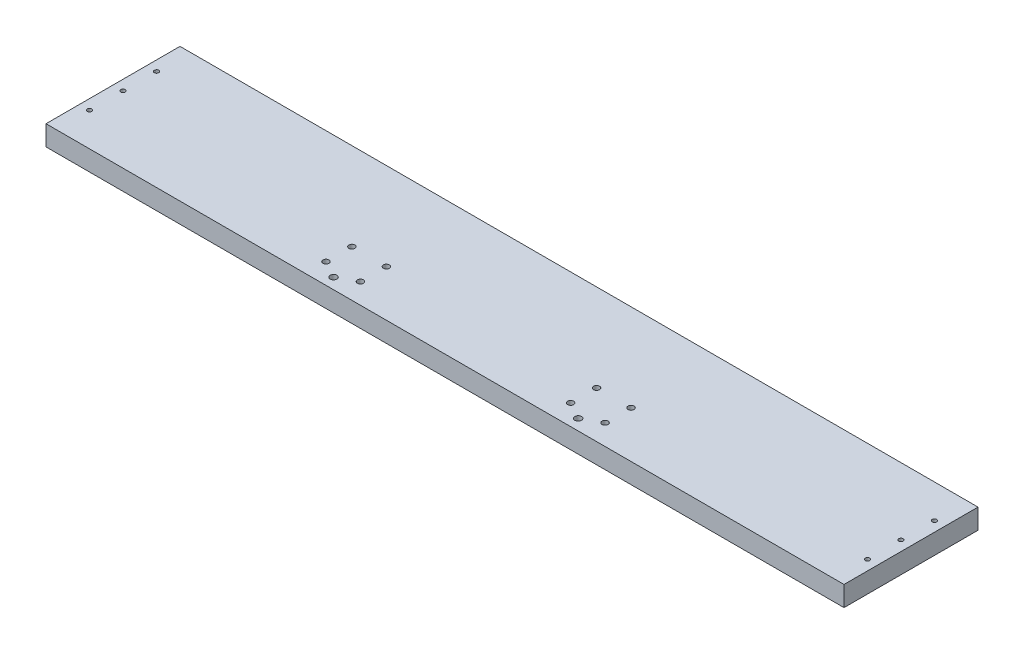
from build123d import *

# Parameters (mm, degrees)
SKETCH2_W           = 756.412
SKETCH2_H           = 127
BOSS_EXTRUDE1_DEPTH = 19.05
CUT_EXTRUDE1_REACH  = 21.05
SKETCH3_R           = 2.85115
CUT_EXTRUDE2_REACH  = 21.05
SKETCH4_R           = 3.175
CUT_EXTRUDE3_REACH  = 21.05
SKETCH5_R           = 2.0828


with BuildPart() as part:
    # Sketch2 → Boss-Extrude1 (new body)
    with BuildSketch(Plane(origin=(0, 0, 0), x_dir=(1, 0, 0), z_dir=(0, 1, 0))):
        with Locations((378.206, 63.5)):
            Rectangle(SKETCH2_W, SKETCH2_H)
    extrude(amount=BOSS_EXTRUDE1_DEPTH)

    # Sketch3 → Cut-Extrude1 (cut, up to next)
    with BuildSketch(Plane(origin=(0, 19.05, 0), x_dir=(1, 0, 0), z_dir=(0, 1, 0)), mode=Mode.PRIVATE) as cut_extrude1_sk1:
        with Locations((245.92915, 19.46275)):
            Circle(SKETCH3_R)
    cut_extrude1_tool1 = extrude(cut_extrude1_sk1.sketch, amount=-CUT_EXTRUDE1_REACH, mode=Mode.PRIVATE) & part.part
    add(cut_extrude1_tool1.solids().sort_by_distance((245.92915, 19.05, -19.46275))[0], mode=Mode.SUBTRACT)
    # Sketch3 → Cut-Extrude1 (cut, up to next)
    with BuildSketch(Plane(origin=(0, 19.05, 0), x_dir=(1, 0, 0), z_dir=(0, 1, 0)), mode=Mode.PRIVATE) as cut_extrude1_sk2:
        with Locations((278.58085, 19.46275)):
            Circle(SKETCH3_R)
    cut_extrude1_tool2 = extrude(cut_extrude1_sk2.sketch, amount=-CUT_EXTRUDE1_REACH, mode=Mode.PRIVATE) & part.part
    add(cut_extrude1_tool2.solids().sort_by_distance((278.58085, 19.05, -19.46275))[0], mode=Mode.SUBTRACT)
    # Sketch3 → Cut-Extrude1 (cut, up to next)
    with BuildSketch(Plane(origin=(0, 19.05, 0), x_dir=(1, 0, 0), z_dir=(0, 1, 0)), mode=Mode.PRIVATE) as cut_extrude1_sk3:
        with Locations((278.58085, 44.03725)):
            Circle(SKETCH3_R)
    cut_extrude1_tool3 = extrude(cut_extrude1_sk3.sketch, amount=-CUT_EXTRUDE1_REACH, mode=Mode.PRIVATE) & part.part
    add(cut_extrude1_tool3.solids().sort_by_distance((278.58085, 19.05, -44.03725))[0], mode=Mode.SUBTRACT)
    # Sketch3 → Cut-Extrude1 (cut, up to next)
    with BuildSketch(Plane(origin=(0, 19.05, 0), x_dir=(1, 0, 0), z_dir=(0, 1, 0)), mode=Mode.PRIVATE) as cut_extrude1_sk4:
        with Locations((245.92915, 44.03725)):
            Circle(SKETCH3_R)
    cut_extrude1_tool4 = extrude(cut_extrude1_sk4.sketch, amount=-CUT_EXTRUDE1_REACH, mode=Mode.PRIVATE) & part.part
    add(cut_extrude1_tool4.solids().sort_by_distance((245.92915, 19.05, -44.03725))[0], mode=Mode.SUBTRACT)
    # Sketch3 → Cut-Extrude1 (cut, up to next)
    with BuildSketch(Plane(origin=(0, 19.05, 0), x_dir=(1, 0, 0), z_dir=(0, 1, 0)), mode=Mode.PRIVATE) as cut_extrude1_sk5:
        with Locations((477.83115, 19.46275)):
            Circle(SKETCH3_R)
    cut_extrude1_tool5 = extrude(cut_extrude1_sk5.sketch, amount=-CUT_EXTRUDE1_REACH, mode=Mode.PRIVATE) & part.part
    add(cut_extrude1_tool5.solids().sort_by_distance((477.83115, 19.05, -19.46275))[0], mode=Mode.SUBTRACT)
    # Sketch3 → Cut-Extrude1 (cut, up to next)
    with BuildSketch(Plane(origin=(0, 19.05, 0), x_dir=(1, 0, 0), z_dir=(0, 1, 0)), mode=Mode.PRIVATE) as cut_extrude1_sk6:
        with Locations((510.48285, 19.46275)):
            Circle(SKETCH3_R)
    cut_extrude1_tool6 = extrude(cut_extrude1_sk6.sketch, amount=-CUT_EXTRUDE1_REACH, mode=Mode.PRIVATE) & part.part
    add(cut_extrude1_tool6.solids().sort_by_distance((510.48285, 19.05, -19.46275))[0], mode=Mode.SUBTRACT)
    # Sketch3 → Cut-Extrude1 (cut, up to next)
    with BuildSketch(Plane(origin=(0, 19.05, 0), x_dir=(1, 0, 0), z_dir=(0, 1, 0)), mode=Mode.PRIVATE) as cut_extrude1_sk7:
        with Locations((510.48285, 44.03725)):
            Circle(SKETCH3_R)
    cut_extrude1_tool7 = extrude(cut_extrude1_sk7.sketch, amount=-CUT_EXTRUDE1_REACH, mode=Mode.PRIVATE) & part.part
    add(cut_extrude1_tool7.solids().sort_by_distance((510.48285, 19.05, -44.03725))[0], mode=Mode.SUBTRACT)
    # Sketch3 → Cut-Extrude1 (cut, up to next)
    with BuildSketch(Plane(origin=(0, 19.05, 0), x_dir=(1, 0, 0), z_dir=(0, 1, 0)), mode=Mode.PRIVATE) as cut_extrude1_sk8:
        with Locations((477.83115, 44.03725)):
            Circle(SKETCH3_R)
    cut_extrude1_tool8 = extrude(cut_extrude1_sk8.sketch, amount=-CUT_EXTRUDE1_REACH, mode=Mode.PRIVATE) & part.part
    add(cut_extrude1_tool8.solids().sort_by_distance((477.83115, 19.05, -44.03725))[0], mode=Mode.SUBTRACT)

    # Sketch4 → Cut-Extrude2 (cut, up to next)
    with BuildSketch(Plane(origin=(0, 19.05, 0), x_dir=(1, 0, 0), z_dir=(0, 1, 0)), mode=Mode.PRIVATE) as cut_extrude2_sk1:
        with Locations((494.157, 10.31875)):
            Circle(SKETCH4_R)
    cut_extrude2_tool1 = extrude(cut_extrude2_sk1.sketch, amount=-CUT_EXTRUDE2_REACH, mode=Mode.PRIVATE) & part.part
    add(cut_extrude2_tool1.solids().sort_by_distance((494.157, 19.05, -10.31875))[0], mode=Mode.SUBTRACT)
    # Sketch4 → Cut-Extrude2 (cut, up to next)
    with BuildSketch(Plane(origin=(0, 19.05, 0), x_dir=(1, 0, 0), z_dir=(0, 1, 0)), mode=Mode.PRIVATE) as cut_extrude2_sk2:
        with Locations((262.255, 10.31875)):
            Circle(SKETCH4_R)
    cut_extrude2_tool2 = extrude(cut_extrude2_sk2.sketch, amount=-CUT_EXTRUDE2_REACH, mode=Mode.PRIVATE) & part.part
    add(cut_extrude2_tool2.solids().sort_by_distance((262.255, 19.05, -10.31875))[0], mode=Mode.SUBTRACT)

    # Sketch5 → Cut-Extrude3 (cut, up to next)
    with BuildSketch(Plane(origin=(0, 19.05, 0), x_dir=(1, 0, 0), z_dir=(0, 1, 0)), mode=Mode.PRIVATE) as cut_extrude3_sk1:
        with Locations((9.525, 95.25)):
            Circle(SKETCH5_R)
    cut_extrude3_tool1 = extrude(cut_extrude3_sk1.sketch, amount=-CUT_EXTRUDE3_REACH, mode=Mode.PRIVATE) & part.part
    add(cut_extrude3_tool1.solids().sort_by_distance((9.525, 19.05, -95.25))[0], mode=Mode.SUBTRACT)
    # Sketch5 → Cut-Extrude3 (cut, up to next)
    with BuildSketch(Plane(origin=(0, 19.05, 0), x_dir=(1, 0, 0), z_dir=(0, 1, 0)), mode=Mode.PRIVATE) as cut_extrude3_sk2:
        with Locations((9.525, 63.5)):
            Circle(SKETCH5_R)
    cut_extrude3_tool2 = extrude(cut_extrude3_sk2.sketch, amount=-CUT_EXTRUDE3_REACH, mode=Mode.PRIVATE) & part.part
    add(cut_extrude3_tool2.solids().sort_by_distance((9.525, 19.05, -63.5))[0], mode=Mode.SUBTRACT)
    # Sketch5 → Cut-Extrude3 (cut, up to next)
    with BuildSketch(Plane(origin=(0, 19.05, 0), x_dir=(1, 0, 0), z_dir=(0, 1, 0)), mode=Mode.PRIVATE) as cut_extrude3_sk3:
        with Locations((9.525, 31.75)):
            Circle(SKETCH5_R)
    cut_extrude3_tool3 = extrude(cut_extrude3_sk3.sketch, amount=-CUT_EXTRUDE3_REACH, mode=Mode.PRIVATE) & part.part
    add(cut_extrude3_tool3.solids().sort_by_distance((9.525, 19.05, -31.75))[0], mode=Mode.SUBTRACT)
    # Sketch5 → Cut-Extrude3 (cut, up to next)
    with BuildSketch(Plane(origin=(0, 19.05, 0), x_dir=(1, 0, 0), z_dir=(0, 1, 0)), mode=Mode.PRIVATE) as cut_extrude3_sk4:
        with Locations((746.887, 31.75)):
            Circle(SKETCH5_R)
    cut_extrude3_tool4 = extrude(cut_extrude3_sk4.sketch, amount=-CUT_EXTRUDE3_REACH, mode=Mode.PRIVATE) & part.part
    add(cut_extrude3_tool4.solids().sort_by_distance((746.887, 19.05, -31.75))[0], mode=Mode.SUBTRACT)
    # Sketch5 → Cut-Extrude3 (cut, up to next)
    with BuildSketch(Plane(origin=(0, 19.05, 0), x_dir=(1, 0, 0), z_dir=(0, 1, 0)), mode=Mode.PRIVATE) as cut_extrude3_sk5:
        with Locations((746.887, 63.5)):
            Circle(SKETCH5_R)
    cut_extrude3_tool5 = extrude(cut_extrude3_sk5.sketch, amount=-CUT_EXTRUDE3_REACH, mode=Mode.PRIVATE) & part.part
    add(cut_extrude3_tool5.solids().sort_by_distance((746.887, 19.05, -63.5))[0], mode=Mode.SUBTRACT)
    # Sketch5 → Cut-Extrude3 (cut, up to next)
    with BuildSketch(Plane(origin=(0, 19.05, 0), x_dir=(1, 0, 0), z_dir=(0, 1, 0)), mode=Mode.PRIVATE) as cut_extrude3_sk6:
        with Locations((746.887, 95.25)):
            Circle(SKETCH5_R)
    cut_extrude3_tool6 = extrude(cut_extrude3_sk6.sketch, amount=-CUT_EXTRUDE3_REACH, mode=Mode.PRIVATE) & part.part
    add(cut_extrude3_tool6.solids().sort_by_distance((746.887, 19.05, -95.25))[0], mode=Mode.SUBTRACT)


solid = part.part
